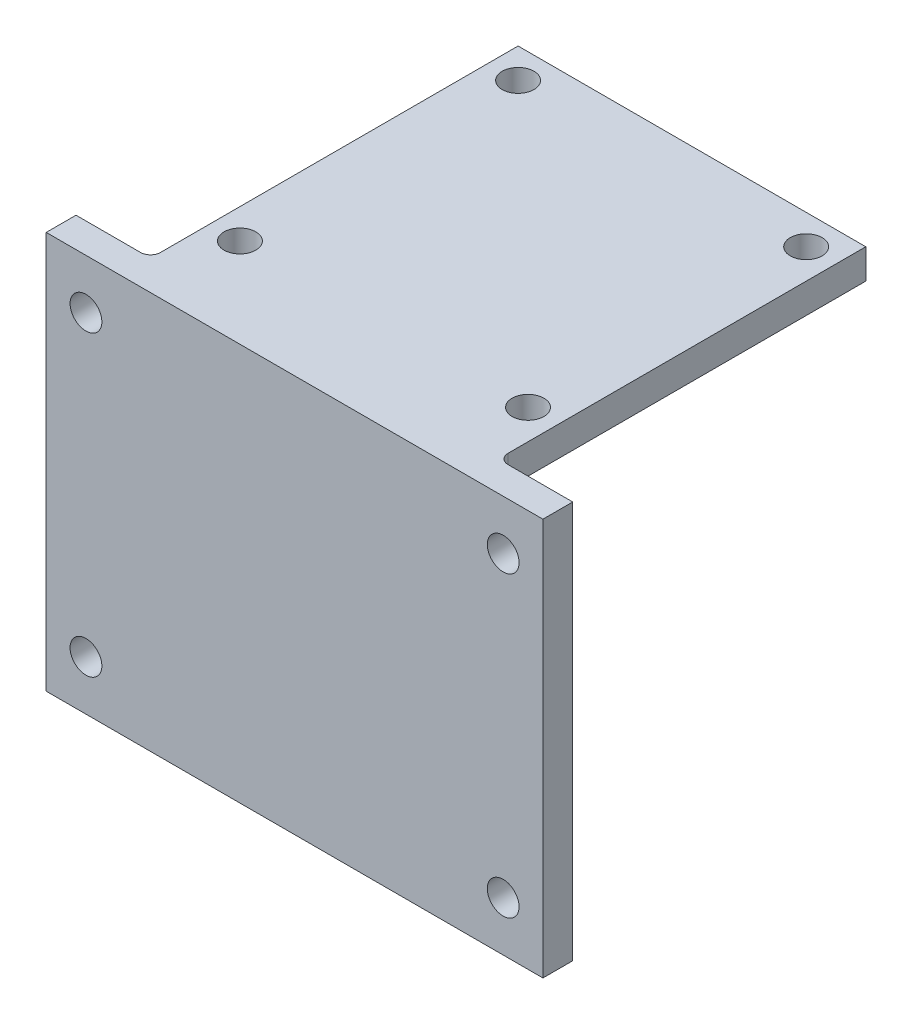
from build123d import *

# Parameters (mm, degrees)
SKETCH1_W           = 35
SKETCH1_H           = 37
SKETCH1_R           = 1.6
BOSS_EXTRUDE1_DEPTH = 3
SKETCH2_W           = 50
SKETCH2_H           = 40
SKETCH2_R           = 1.6
BOSS_EXTRUDE2_DEPTH = 3
FILLET1_R           = 3
FILLET2_R           = 1
FILLET3_R           = 1


with BuildPart() as part:
    # Sketch1 → Boss-Extrude1 (new body)
    with BuildSketch(Plane(origin=(0, 0, 0), x_dir=(1, 0, 0), z_dir=(0, 1, 0))):
        with Locations((2.595206121, -4.992767018)):
            Rectangle(SKETCH1_W, SKETCH1_H)
        with Locations((-11.904793879, 10.507232982)):
            Circle(SKETCH1_R, mode=Mode.SUBTRACT)
        with Locations((-11.904793879, -17.492767018)):
            Circle(SKETCH1_R, mode=Mode.SUBTRACT)
        with Locations((17.095206121, -17.492767018)):
            Circle(SKETCH1_R, mode=Mode.SUBTRACT)
        with Locations((17.095206121, 10.507232982)):
            Circle(SKETCH1_R, mode=Mode.SUBTRACT)
    extrude(amount=BOSS_EXTRUDE1_DEPTH)

    # Sketch2 → Boss-Extrude2 (add)
    with BuildSketch(Plane.XY.offset(23.492767018)):
        with Locations((2.595206121, -17)):
            Rectangle(SKETCH2_W, SKETCH2_H)
        with Locations((23.595206121, -32)):
            Circle(SKETCH2_R, mode=Mode.SUBTRACT)
        with Locations((23.595206121, -2)):
            Circle(SKETCH2_R, mode=Mode.SUBTRACT)
        with Locations((-18.404793879, -2)):
            Circle(SKETCH2_R, mode=Mode.SUBTRACT)
        with Locations((-18.404793879, -32)):
            Circle(SKETCH2_R, mode=Mode.SUBTRACT)
    extrude(amount=BOSS_EXTRUDE2_DEPTH)

    # Fillet1
    fillet1_edges = [part.edges().sort_by_distance(p)[0] for p in [
        (2.595206121, 0, 23.492767018),
    ]]
    fillet(fillet1_edges, radius=FILLET1_R)

    # Fillet2
    fillet2_edges = [part.edges().sort_by_distance(p)[0] for p in [
        (-14.904793879, -1.5, 23.492767018),
    ]]
    fillet(fillet2_edges, radius=FILLET2_R)

    # Fillet3
    fillet3_edges = [part.edges().sort_by_distance(p)[0] for p in [
        (20.095206121, -1.5, 23.492767018),
    ]]
    fillet(fillet3_edges, radius=FILLET3_R)


solid = part.part
